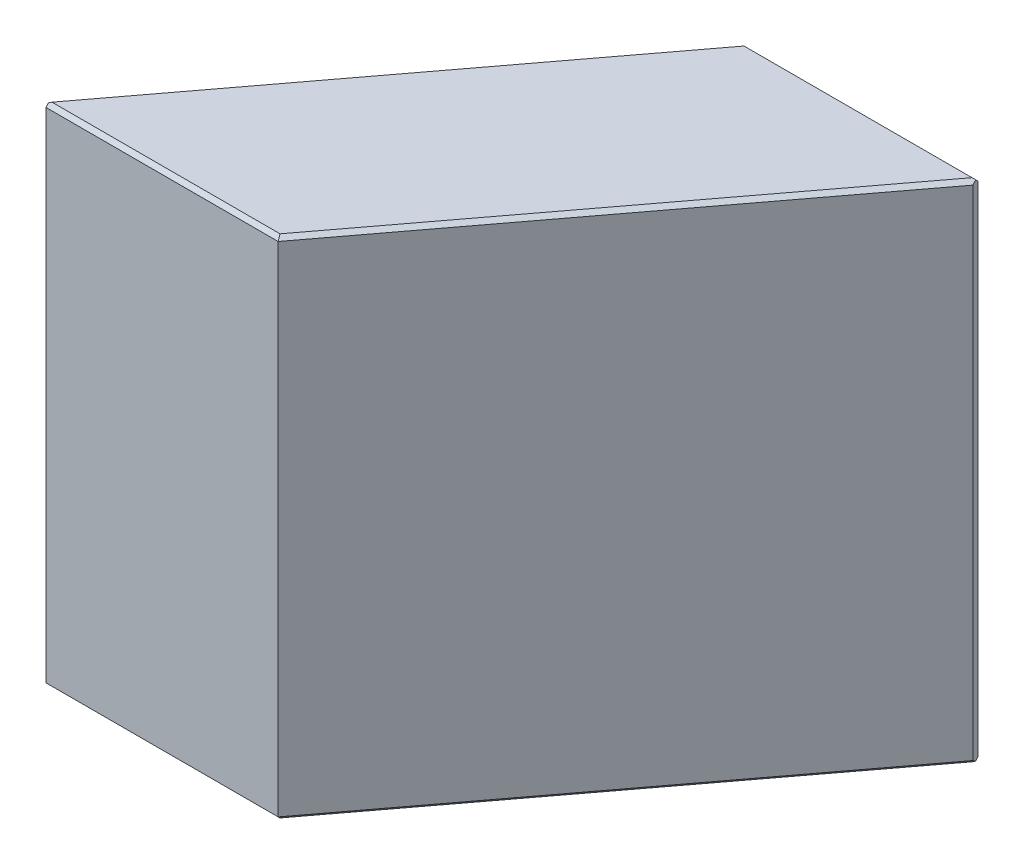
from build123d import *

# Parameters (mm, degrees)
EXTRUDE_1_DEPTH        = 20
CHAMFER_1_SIZE         = 0.15
CHAMFER_2_SIZE2        = 0.3
CHAMFER_2_SIZE         = 0.214216777
CHAMFER_2_EDGE_2_SIZE2 = 0.214216777
CHAMFER_2_EDGE_2_SIZE  = 0.3


with BuildPart() as part:
    # Эскиз1 → Вытянуть1 (new body)
    with BuildSketch(Plane(origin=(0, 0, 0), x_dir=(1, 0, 0), z_dir=(0, 1, 0))):
        Polygon((11.981509397, 15.9), (21.372526833, 15.9), (9.391017436, 0), (0, 0), align=None)
    extrude(amount=EXTRUDE_1_DEPTH)

    # Фаска1
    chamfer_1_edges = [part.edges().sort_by_distance(p)[0] for p in [
        (15.381772134, 20, -7.95),
        (16.677018115, 20, -15.9),
        (5.990754698, 20, -7.95),
        (16.677018115, 0, -15.9),
        (15.381772134, 0, -7.95),
        (4.695508718, 0, 0),
        (5.990754698, 0, -7.95),
        (4.695508718, 20, 0),
    ]]
    chamfer(chamfer_1_edges, length=CHAMFER_1_SIZE)

    # Фаска2
    chamfer_2_edges = [part.edges().sort_by_distance(p)[0] for p in [
        (21.372526833, 10, -15.9),
    ]]
    chamfer(chamfer_2_edges, length=CHAMFER_2_SIZE, length2=CHAMFER_2_SIZE2)

    # Фаска2 edge 2
    chamfer_2_edge_2_edges = [part.edges().sort_by_distance(p)[0] for p in [
        (0, 10, 0),
    ]]
    chamfer(chamfer_2_edge_2_edges, length=CHAMFER_2_EDGE_2_SIZE, length2=CHAMFER_2_EDGE_2_SIZE2)


solid = part.part
